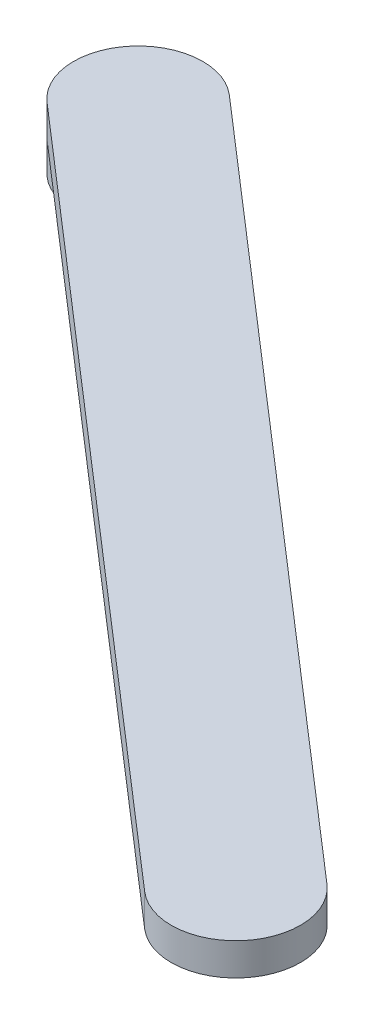
from build123d import *

# Parameters (mm, degrees)
BOSS_EXTRUDE1_DEPTH = 3.175
SKETCH4_R           = 6.35
BOSS_EXTRUDE2_DEPTH = 3.175


with BuildPart() as part:
    # Sketch3 → Boss-Extrude1 (new body)
    with BuildSketch(Plane(origin=(0, 42.21734, 0), x_dir=(1, 0, 0), z_dir=(0, 1, 0))):
        with BuildLine():
            Line((35.908808919, 4.798625676), (-36.070576217, 67.18075946))
            ThreePointArc((-36.070576217, 67.18075946), (-45.028010811, 66.540942703), (-44.388194055, 57.583508109))
            Line((-44.388194055, 57.583508109), (27.591191081, -4.798625676))
            ThreePointArc((27.591191081, -4.798625676), (36.548625676, -4.158808919), (35.908808919, 4.798625676))
        make_face()
    extrude(amount=-BOSS_EXTRUDE1_DEPTH)

    # Sketch4 → Boss-Extrude2 (add)
    with BuildSketch(Plane.XZ.offset(-39.04234)):
        with Locations((-40.229385136, -62.382133784)):
            Circle(SKETCH4_R)
    extrude(amount=BOSS_EXTRUDE2_DEPTH)


solid = part.part
